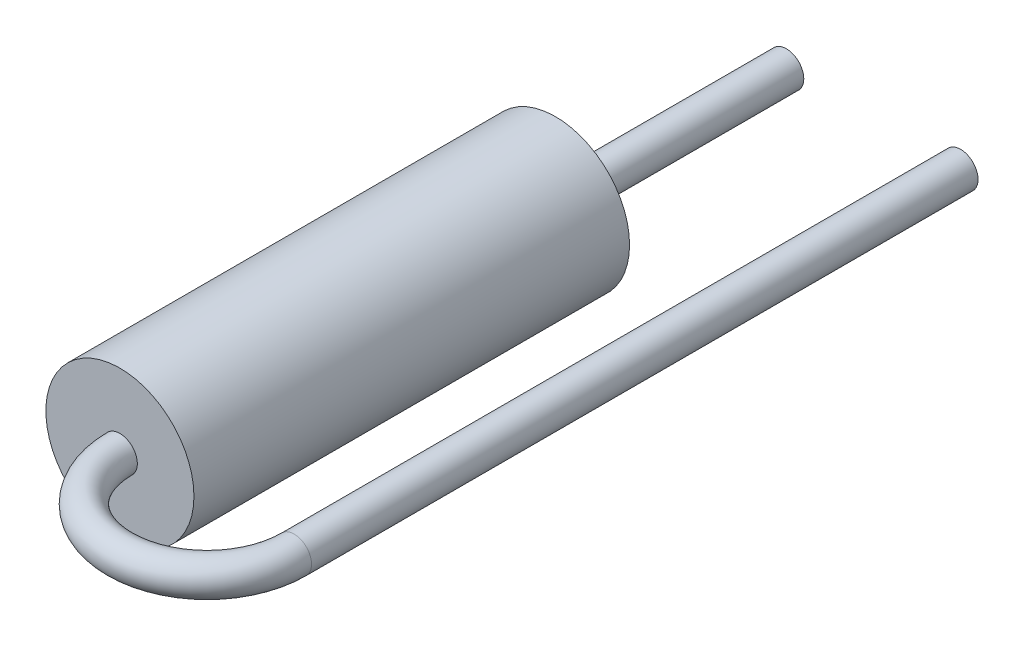
from build123d import *

# Parameters (mm, degrees)
SKETCH2_R           = 1.7
RESISTOR_BODY_DEPTH = 10
LEAD1_PROFILE_R     = 0.4
SKETCH6_R           = 0.4
LEAD2_DEPTH         = 5.3


with BuildPart() as part:
    # Sketch2 → Resistor Body (new body)
    with BuildSketch(Plane.XY):
        Circle(SKETCH2_R)
    extrude(amount=RESISTOR_BODY_DEPTH)

    # Lead1: sweep along a path in Lead1 Path
    with BuildLine(Plane(origin=(0, 0, 0), x_dir=(1, 0, 0), z_dir=(0, 1, 0))) as lead1_path:
        Line((4, 5.3), (4, -10))
        ThreePointArc((4, -10), (2, -12), (0, -10))
    # Lead1 Profile → Lead1 (sweep)
    with BuildSketch(Plane(origin=(0, 0, 10), x_dir=(-1, 0, 0), z_dir=(0, 0, 1))):
        Circle(LEAD1_PROFILE_R)
    sweep(path=lead1_path.line)

    # Sketch6 → Lead2 (add)
    with BuildSketch(Plane(origin=(0, 0, 0), x_dir=(1, 0, 0), z_dir=(0, 0, -1))):
        Circle(SKETCH6_R)
    extrude(amount=LEAD2_DEPTH)


solid = part.part
